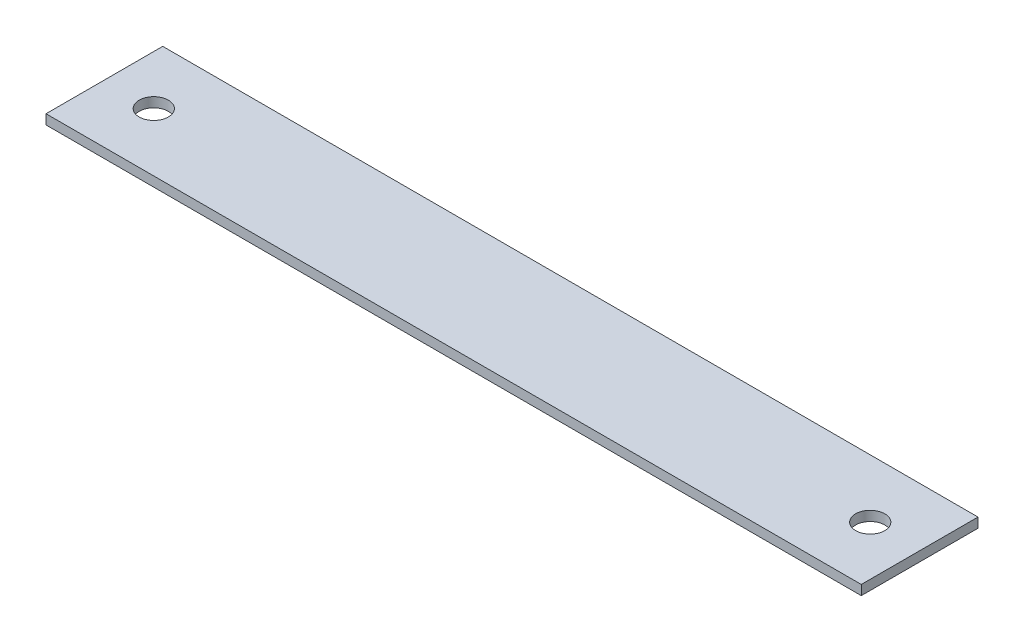
from build123d import *

# Parameters (mm, degrees)
SKETCH1_W           = 419.1
SKETCH1_H           = 60
SKETCH1_R           = 7.5
BOSS_EXTRUDE1_DEPTH = 5


with BuildPart() as part:
    # Sketch1 → Boss-Extrude1 (new body)
    with BuildSketch(Plane(origin=(0, 0, 0), x_dir=(1, 0, 0), z_dir=(0, 1, 0))):
        with Locations((209.55, 30)):
            Rectangle(SKETCH1_W, SKETCH1_H)
        with Locations((393.7, 30)):
            Circle(SKETCH1_R, mode=Mode.SUBTRACT)
        with Locations((25.4, 30)):
            Circle(SKETCH1_R, mode=Mode.SUBTRACT)
    extrude(amount=BOSS_EXTRUDE1_DEPTH)


solid = part.part
